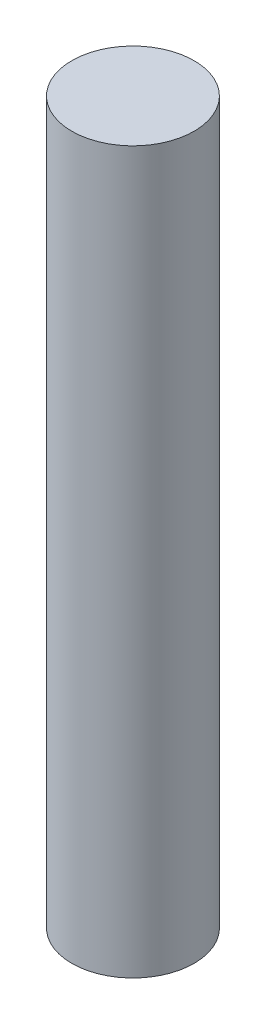
from build123d import *

# Parameters (mm, degrees)
SKETCH1_R           = 6
BOSS_EXTRUDE1_DEPTH = 70.7


with BuildPart() as part:
    # Sketch1 → Boss-Extrude1 (new body)
    with BuildSketch(Plane(origin=(0, 0, 0), x_dir=(1, 0, 0), z_dir=(0, 1, 0))):
        Circle(SKETCH1_R)
    extrude(amount=BOSS_EXTRUDE1_DEPTH)


solid = part.part
